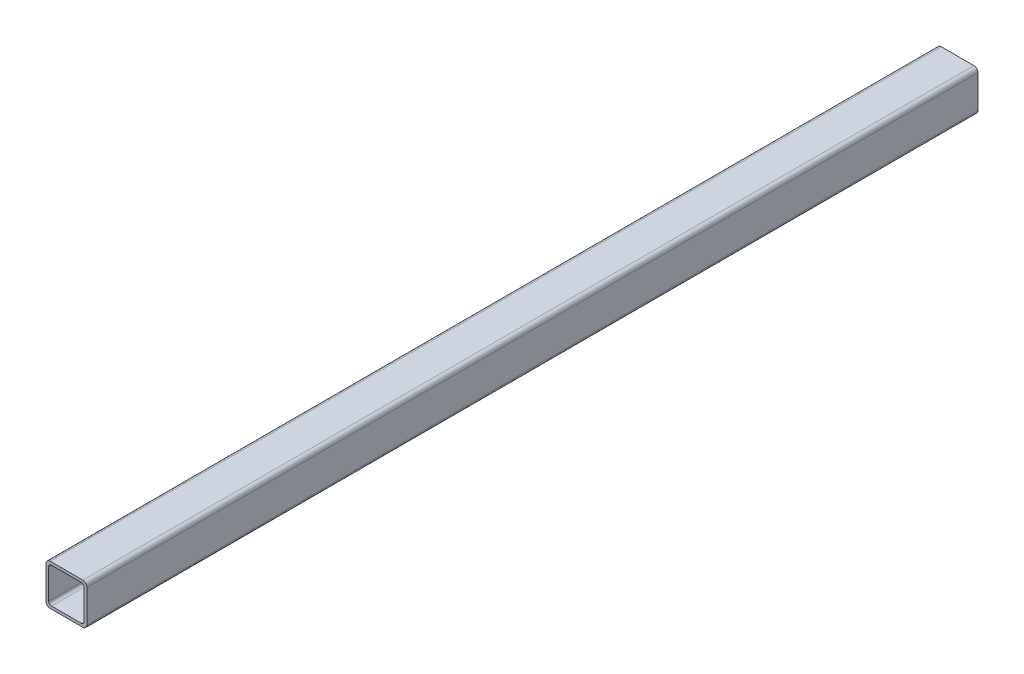
from build123d import *

# Parameters (mm, degrees)
EXTRUDE_1_DEPTH = 327


with BuildPart() as part:
    # Эскиз1 → Бобышка-Вытянуть1 (new body)
    with BuildSketch(Plane.XY):
        with BuildLine():
            Line((-12, 30), (12, 30))
            ThreePointArc((12, 30), (14.121320344, 29.121320344), (15, 27))
            Line((15, 27), (15, 3))
            ThreePointArc((15, 3), (14.121320344, 0.878679656), (12, 0))
            Line((12, 0), (-12, 0))
            ThreePointArc((-12, 0), (-14.121320344, 0.878679656), (-15, 3))
            Line((-15, 3), (-15, 27))
            ThreePointArc((-15, 27), (-14.121320344, 29.121320344), (-12, 30))
        make_face()
        with BuildLine():
            Line((-11, 28), (11, 28))
            ThreePointArc((11, 28), (12.414213562, 27.414213562), (13, 26))
            Line((13, 26), (13, 4))
            ThreePointArc((13, 4), (12.414213562, 2.585786438), (11, 2))
            Line((11, 2), (-11, 2))
            ThreePointArc((-11, 2), (-12.414213562, 2.585786438), (-13, 4))
            Line((-13, 4), (-13, 26))
            ThreePointArc((-13, 26), (-12.414213562, 27.414213562), (-11, 28))
        make_face(mode=Mode.SUBTRACT)
    extrude(amount=EXTRUDE_1_DEPTH)

    # Зеркальное отражение2: part across plane


with BuildPart() as part_1:
    add(part.part)
    add(part.part.mirror(Plane(origin=(-12, 3, 0), x_dir=(1, 0, 0), z_dir=(0, 0, 1))))


solid = part_1.part
